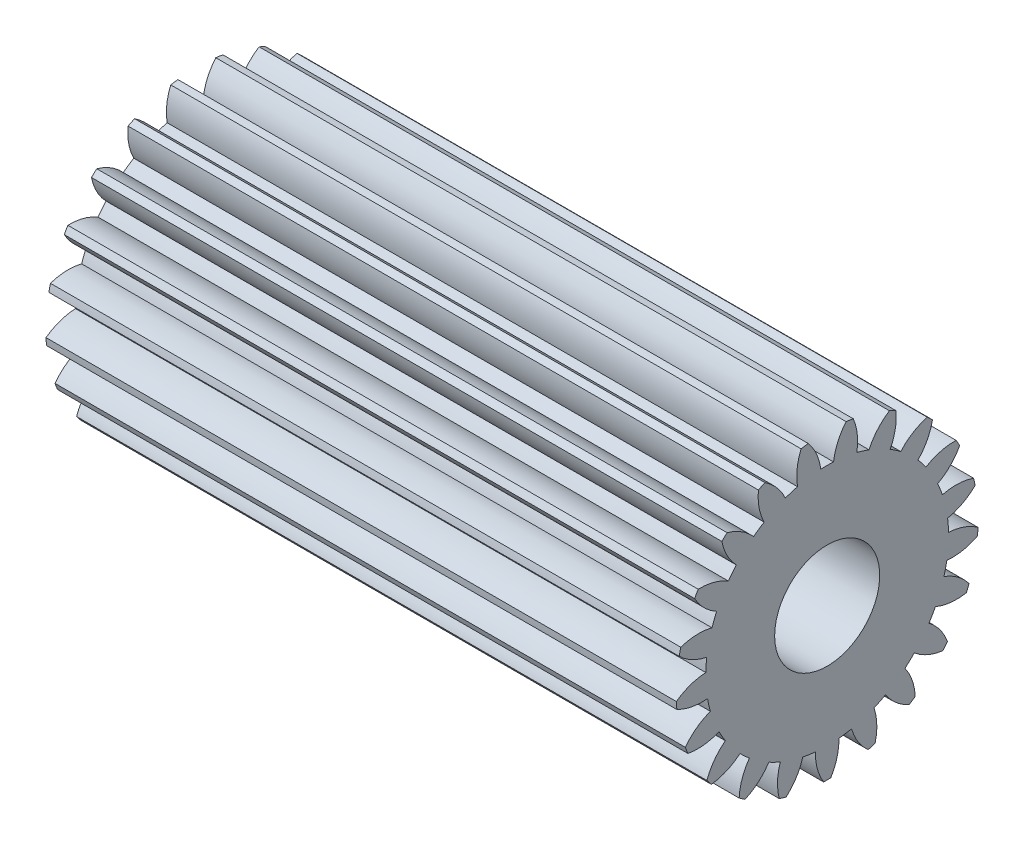
from build123d import *

# Parameters (mm, degrees)
BASPROSKE_W     = 12
BASPROSKE_H     = 2.875
TOOTHCUT_DEPTH  = 13.670092738
TEETHCUTS_COUNT = 21
TEETHCUTS_ANGLE = 342.857142857
BORSKE_R        = 1
BORE_DEPTH      = 50.0000508


with BuildPart() as part:
    # BasProSke → Base-Revolve (revolve)
    with BuildSketch(Plane(origin=(0, 0, 0), x_dir=(1, 0, 0), z_dir=(0, 1, 0)), mode=Mode.PRIVATE) as base_revolve_sk:
        with Locations((6, 1.4375)):
            Rectangle(BASPROSKE_W, BASPROSKE_H)
    revolve(base_revolve_sk.sketch.rotate(Axis((-10, 0, 0), (1, 0, 0)), 180), axis=Axis((-10, 0, 0), (1, 0, 0)))

    # TooCutSke → ToothCut (cut, through all)
    with BuildSketch(Plane(origin=(0, 0, 0), x_dir=(0, 0, -1), z_dir=(1, 0, 0))):
        with BuildLine():
            ThreePointArc((0.121407231, 2.308309454), (0, 2.3115), (-0.121407231, 2.308309454))
            ThreePointArc((-0.121407231, 2.308309454), (-0.207823298, 2.61149035), (-0.380340948, 2.875354052))
            ThreePointArc((-0.380340948, 2.875354052), (0, 2.9004), (0.380340948, 2.875354052))
            ThreePointArc((0.380340948, 2.875354052), (0.207823298, 2.61149035), (0.121407231, 2.308309454))
        make_face()
    toothcut = extrude(amount=TOOTHCUT_DEPTH, mode=Mode.SUBTRACT)

    # TeethCuts: ToothCut ×21 about axis
    teethcuts_axis = Axis((-10, 0, 0), (1, 0, 0))
    for i in range(1, TEETHCUTS_COUNT):
        add(toothcut.rotate(teethcuts_axis, i * TEETHCUTS_ANGLE / (TEETHCUTS_COUNT - 1)), mode=Mode.SUBTRACT)

    # BorSke → Bore (cut, symmetric)
    with BuildSketch(Plane(origin=(0, 0, 0), x_dir=(0, 0, -1), z_dir=(1, 0, 0))):
        with Locations(Location((0, 0, 0), (0, 0, 180))):
            Circle(BORSKE_R)
    extrude(amount=BORE_DEPTH, both=True, mode=Mode.SUBTRACT)


solid = part.part
